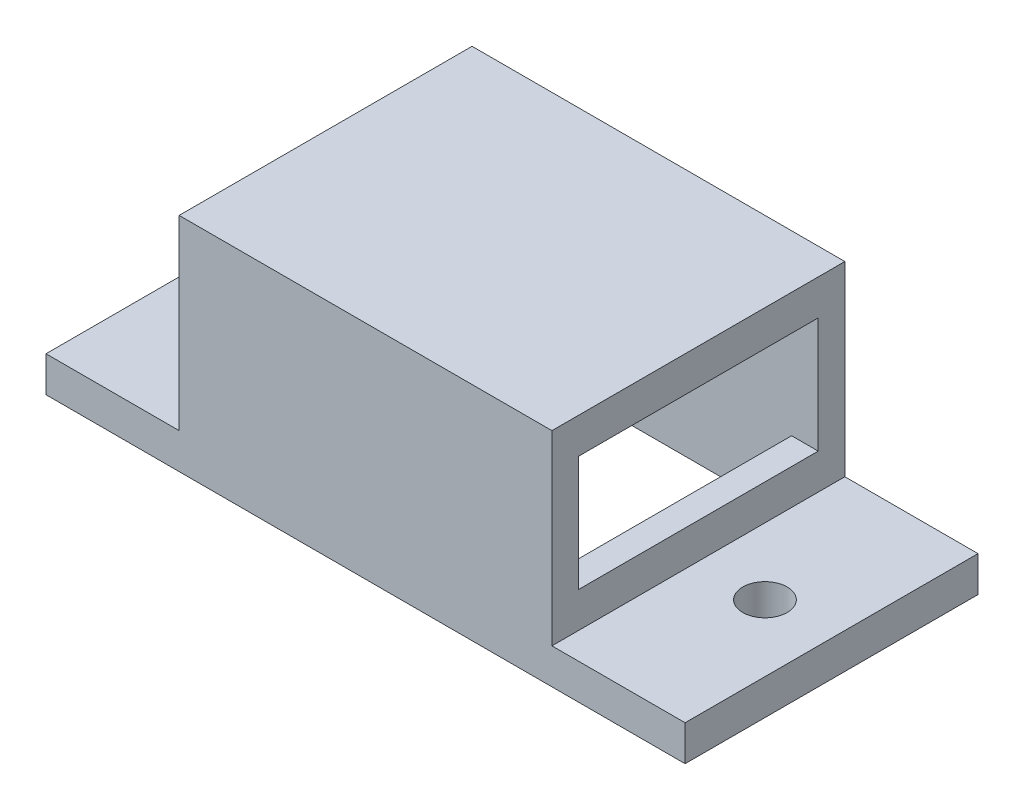
from build123d import *

# Parameters (mm, degrees)
SKETCH_1_W          = 42
SKETCH_1_H          = 33
EXTRUDE_1_DEPTH     = 25
SKETCH_2_W          = 72
SKETCH_2_H          = 33
EXTRUDE_2_DEPTH     = 4
SKETCH_3_W          = 36
SKETCH_3_H          = 27
CUT_EXTRUDE_1_DEPTH = 21
SKETCH_4_W          = 27
SKETCH_4_H          = 13
CUT_EXTRUDE_2_DEPTH = 58
SKETCH_5_R          = 2.5
CUT_EXTRUDE_3_DEPTH = 26


with BuildPart() as part:
    # 草圖1 → 填料-伸長1 (new body)
    with BuildSketch(Plane(origin=(0, 0, 0), x_dir=(1, 0, 0), z_dir=(0, 1, 0))):
        Rectangle(SKETCH_1_W, SKETCH_1_H)
    extrude(amount=EXTRUDE_1_DEPTH)

    # 草圖2 → 填料-伸長2 (add)
    with BuildSketch(Plane(origin=(0, 0, 0), x_dir=(1, 0, 0), z_dir=(0, 1, 0))):
        Rectangle(SKETCH_2_W, SKETCH_2_H)
    extrude(amount=EXTRUDE_2_DEPTH)

    # 草圖3 → 除料-伸長1 (cut)
    with BuildSketch(Plane.XZ):
        Rectangle(SKETCH_3_W, SKETCH_3_H)
    extrude(amount=-CUT_EXTRUDE_1_DEPTH, mode=Mode.SUBTRACT)

    # 草圖4 → 除料-伸長2 (cut, through all)
    with BuildSketch(Plane.ZY.offset(21)):
        with Locations((0, 14.5)):
            Rectangle(SKETCH_4_W, SKETCH_4_H)
    extrude(amount=-CUT_EXTRUDE_2_DEPTH, mode=Mode.SUBTRACT)

    # 草圖5 → 除料-伸長3 (cut, through all)
    with BuildSketch(Plane.XZ):
        with Locations((28.5, 0)):
            Circle(SKETCH_5_R)
        with Locations((-28.5, 0)):
            Circle(SKETCH_5_R)
    extrude(amount=-CUT_EXTRUDE_3_DEPTH, mode=Mode.SUBTRACT)


solid = part.part
